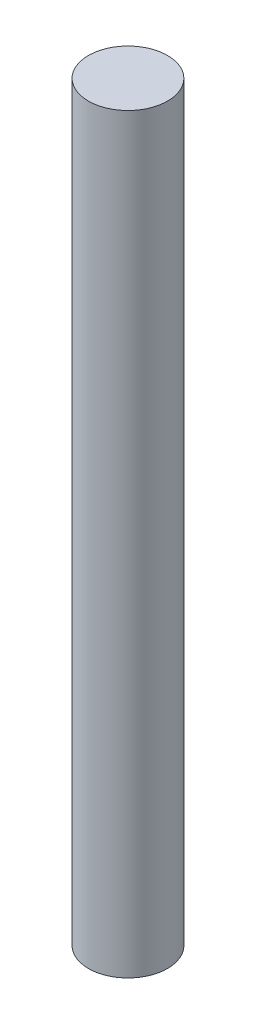
from build123d import *

# Parameters (mm, degrees)
CROQUIS1_R              = 20
SALIENTE_EXTRUIR1_DEPTH = 380


with BuildPart() as part:
    # Croquis1 → Saliente-Extruir1 (new body)
    with BuildSketch(Plane(origin=(0, 0, 0), x_dir=(1, 0, 0), z_dir=(0, 1, 0))):
        Circle(CROQUIS1_R)
    extrude(amount=SALIENTE_EXTRUIR1_DEPTH)


solid = part.part
